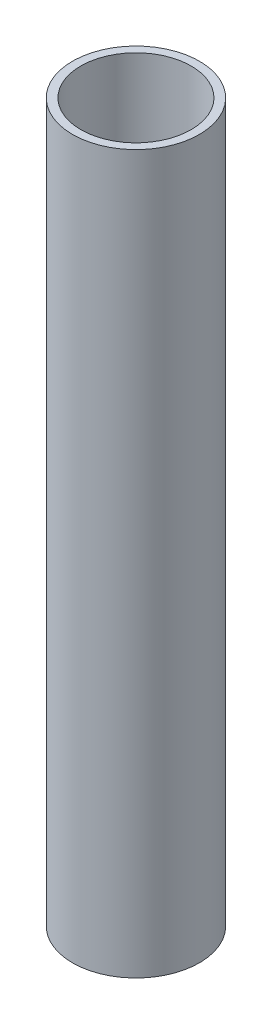
from build123d import *

# Parameters (mm, degrees)
SKETCH_1_R      = 23
SKETCH_1_R_2    = 20
EXTRUDE_1_DEPTH = 260


with BuildPart() as part:
    # 草圖1 → 填料-伸長1 (new body)
    with BuildSketch(Plane(origin=(0, 0, 0), x_dir=(1, 0, 0), z_dir=(0, 1, 0))):
        Circle(SKETCH_1_R)
        Circle(SKETCH_1_R_2, mode=Mode.SUBTRACT)
    extrude(amount=EXTRUDE_1_DEPTH)


solid = part.part
